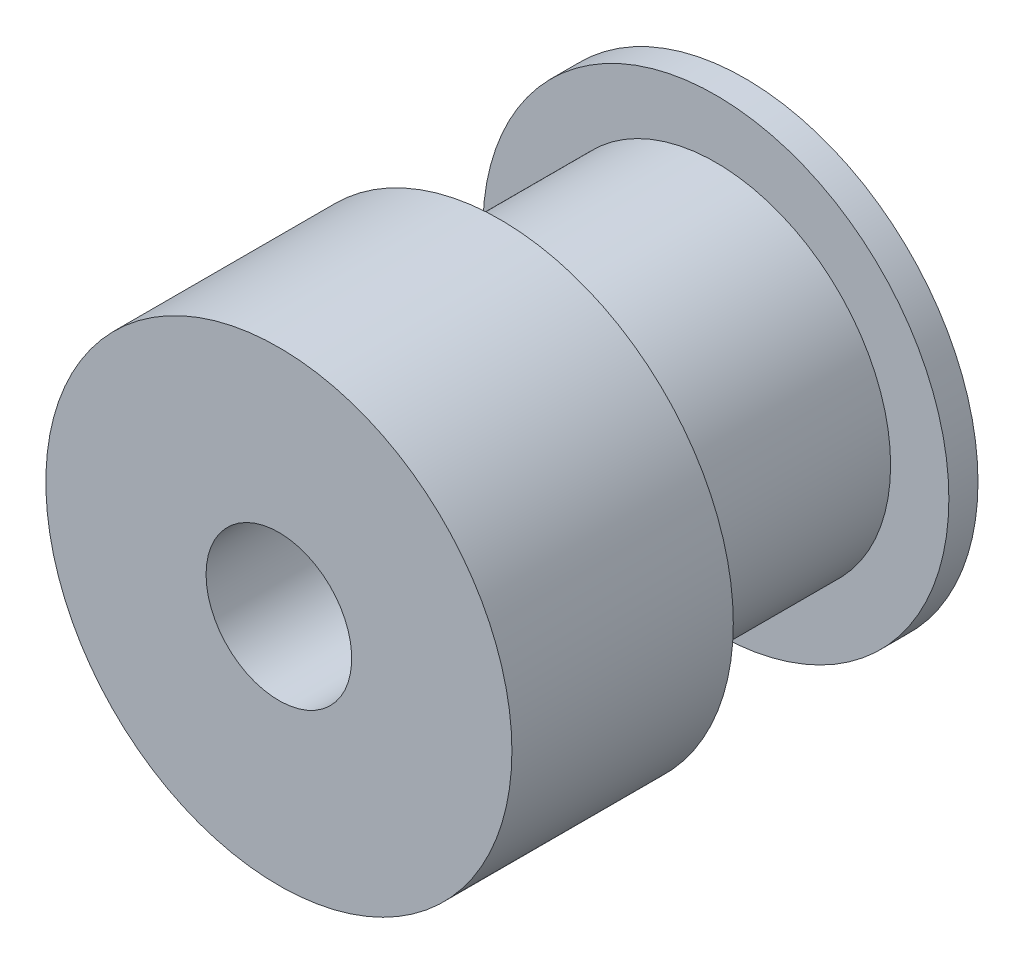
from build123d import *

# Parameters (mm, degrees)
SKETCH_1_R          = 8
EXTRUDE_1_DEPTH     = 1
SKETCH_2_R          = 6
EXTRUDE_2_DEPTH     = 7.4
SKETCH_3_R          = 8
EXTRUDE_3_DEPTH     = 7.6
SKETCH_4_R          = 2.5
CUT_EXTRUDE_1_DEPTH = 17


with BuildPart() as part:
    # 草图1 → 凸台-拉伸1 (new body)
    with BuildSketch(Plane.XY):
        Circle(SKETCH_1_R)
    extrude(amount=EXTRUDE_1_DEPTH)

    # 草图2 → 凸台-拉伸2 (add)
    with BuildSketch(Plane.XY.offset(1)):
        Circle(SKETCH_2_R)
    extrude(amount=EXTRUDE_2_DEPTH)

    # 草图3 → 凸台-拉伸3 (add)
    with BuildSketch(Plane.XY.offset(8.4)):
        Circle(SKETCH_3_R)
    extrude(amount=EXTRUDE_3_DEPTH)

    # 草图4 → 切除-拉伸1 (cut, through all)
    with BuildSketch(Plane(origin=(0, 0, 0), x_dir=(-1, 0, 0), z_dir=(0, 0, -1))):
        Circle(SKETCH_4_R)
    extrude(amount=-CUT_EXTRUDE_1_DEPTH, mode=Mode.SUBTRACT)


solid = part.part
